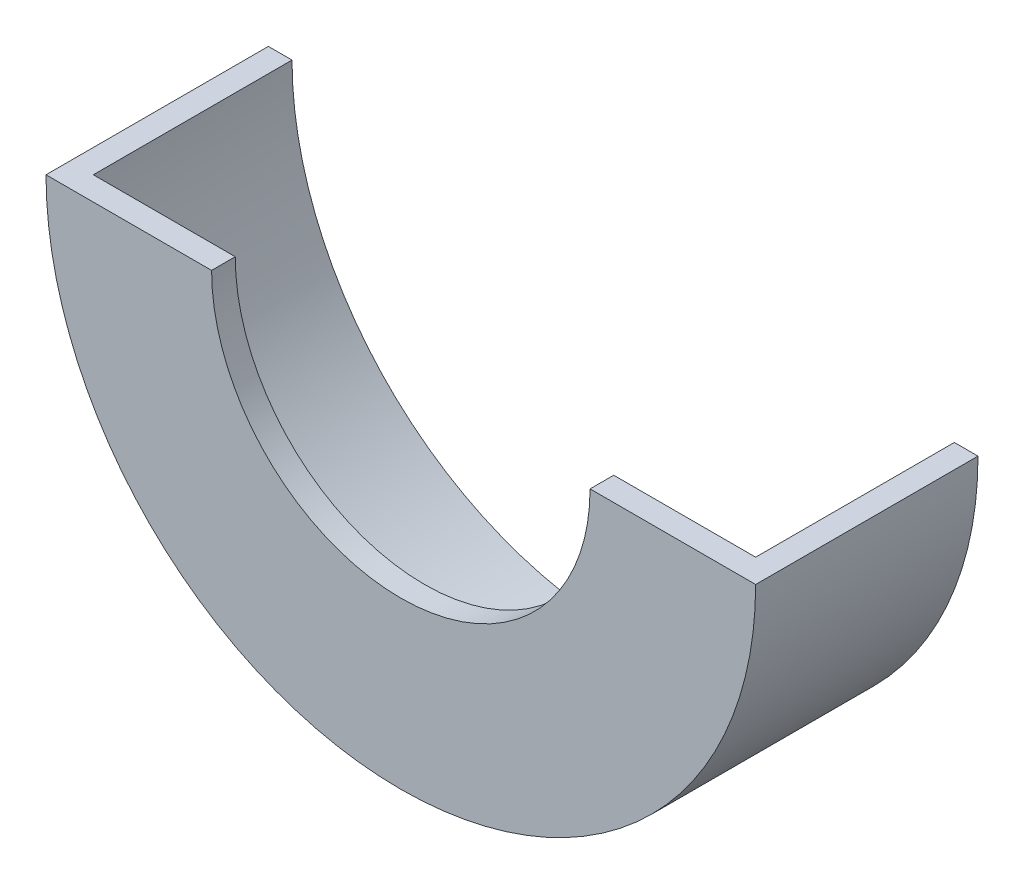
from build123d import *

# Parameters (mm, degrees)
BOSS_EXTRUDE1_DEPTH = 42
BOSS_EXTRUDE2_DEPTH = 5


with BuildPart() as part:
    # Sketch1 → Boss-Extrude1 (new body)
    with BuildSketch(Plane.XY):
        with BuildLine():
            Line((75, 0), (70, 0))
            ThreePointArc((70, 0), (0, -70), (-70, 0))
            Line((-70, 0), (-75, 0))
            ThreePointArc((-75, 0), (0, -75), (75, 0))
        make_face()
    extrude(amount=BOSS_EXTRUDE1_DEPTH)

    # Sketch2 → Boss-Extrude2 (add)
    with BuildSketch(Plane.XY.offset(42)):
        with BuildLine():
            Line((75, 0), (70, 0))
            ThreePointArc((70, 0), (0, -70), (-70, 0))
            Line((-70, 0), (-75, 0))
            ThreePointArc((-75, 0), (0, -75), (75, 0))
        make_face()
        with BuildLine():
            Line((-40, 0), (-70, 0))
            ThreePointArc((-70, 0), (0, -70), (70, 0))
            Line((70, 0), (40, 0))
            ThreePointArc((40, 0), (0, -40), (-40, 0))
        make_face()
    extrude(amount=BOSS_EXTRUDE2_DEPTH)


solid = part.part
